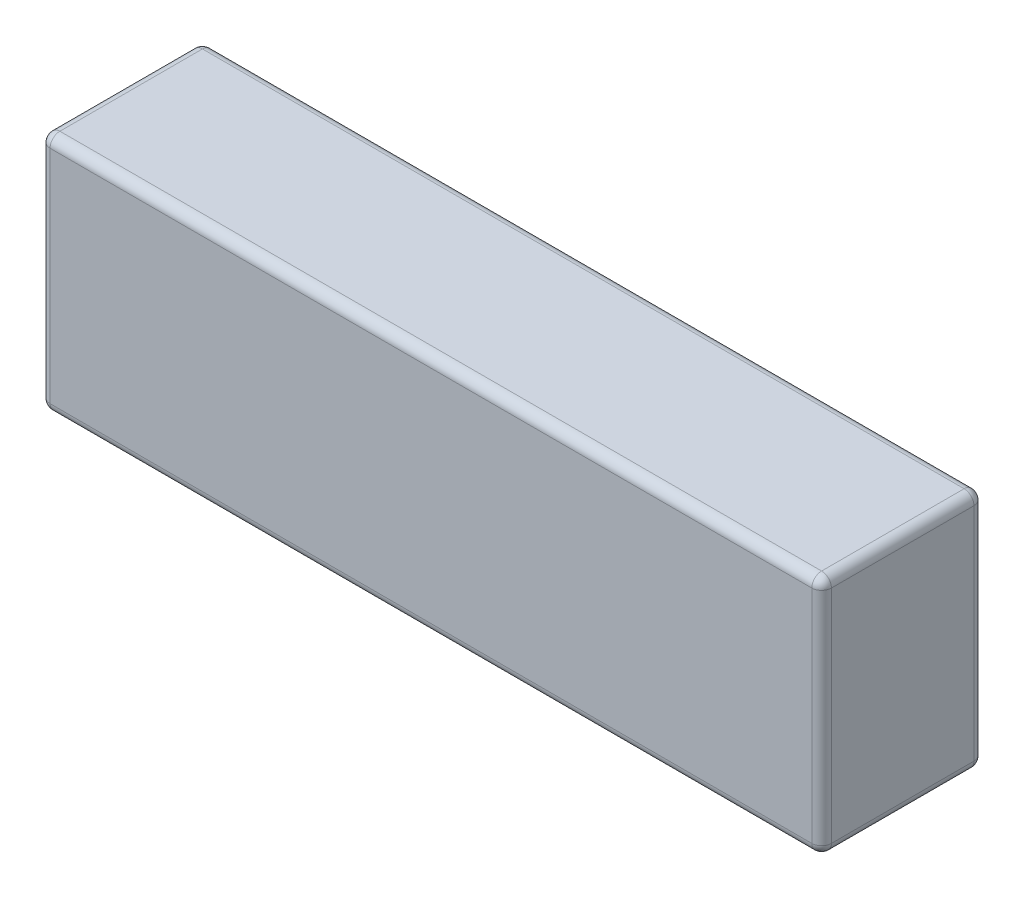
from build123d import *

# Parameters (mm, degrees)
SKETCH1_W           = 159
SKETCH1_H           = 33
BOSS_EXTRUDE1_DEPTH = 49
FILLET1_R           = 2


with BuildPart() as part:
    # Sketch1 → Boss-Extrude1 (new body)
    with BuildSketch(Plane(origin=(0, 0, 0), x_dir=(1, 0, 0), z_dir=(0, 1, 0))):
        with Locations((79.5, 16.5)):
            Rectangle(SKETCH1_W, SKETCH1_H)
    extrude(amount=BOSS_EXTRUDE1_DEPTH)

    # Fillet1
    fillet1_edges = [part.edges().sort_by_distance(p)[0] for p in [
        (159, 49, -16.5),
        (79.5, 49, -33),
        (0, 49, -16.5),
        (79.5, 0, -33),
        (159, 0, -16.5),
        (79.5, 0, 0),
        (0, 0, -16.5),
        (79.5, 49, 0),
        (0, 24.5, -33),
        (159, 24.5, -33),
        (159, 24.5, 0),
        (0, 24.5, 0),
    ]]
    fillet(fillet1_edges, radius=FILLET1_R)


solid = part.part
